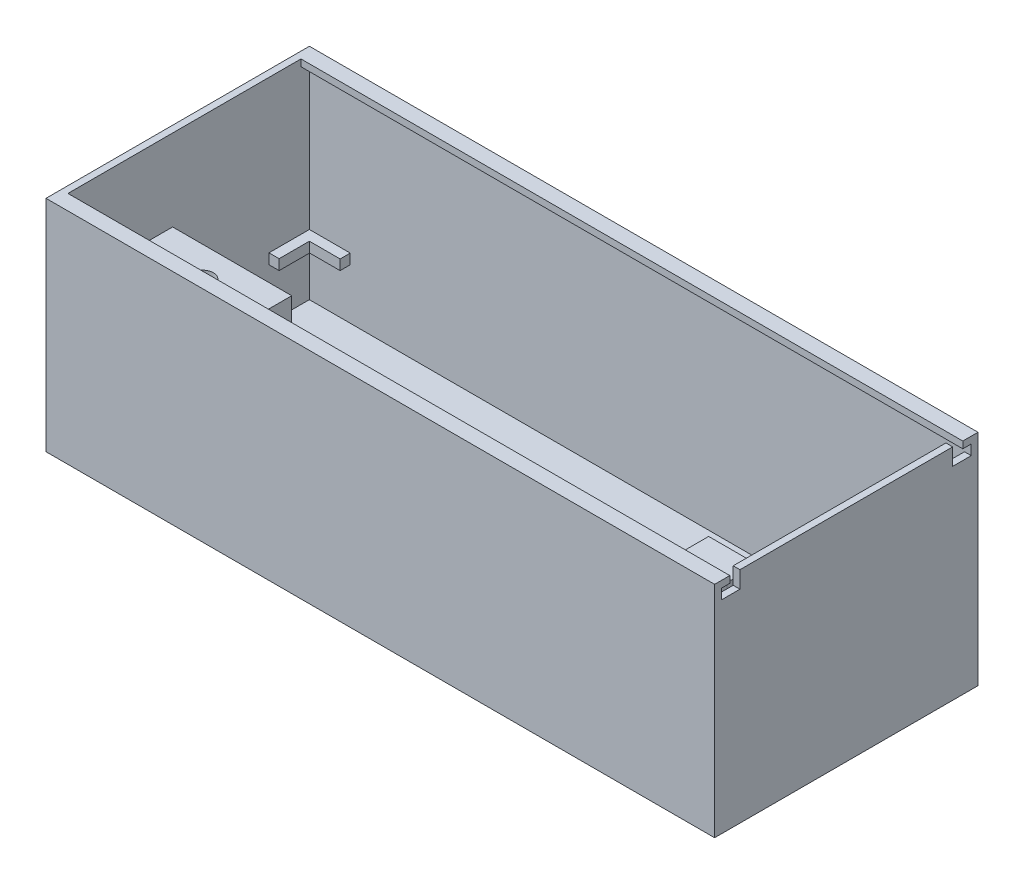
from build123d import *

# Parameters (mm, degrees)
SKETCH2_W                = 198
SKETCH2_H                = 78
BOSS_EXTRUDE1_DEPTH      = 50
BOSS_EXTRUDE1_DEPTH_BACK = 15
SHELL1_T                 = -2
BOSS_EXTRUDE2_REACH      = 198
SKETCH3_W                = 2.5
SKETCH3_H                = 2
CUT_EXTRUDE1_REACH       = 4
CROQUIS1_W               = 35.265
CROQUIS1_H               = 26
SALIENTE_EXTRUIR1_DEPTH  = 38.9
CORTAR_EXTRUIR1_DEPTH    = 2
CORTAR_EXTRUIR2_DEPTH    = 30
CROQUIS5_W               = 26
CROQUIS5_H               = 15
CORTAR_EXTRUIR3_DEPTH    = 35.265
CROQUIS6_W               = 12
CROQUIS6_H               = 3
SALIENTE_EXTRUIR2_DEPTH  = 3
CROQUIS7_W               = 26
CROQUIS7_H               = 15
CORTAR_EXTRUIR4_DEPTH    = 35.265
CROQUIS8_W               = 12
CROQUIS8_H               = 3
SALIENTE_EXTRUIR4_DEPTH  = 3
CROQUIS10_W              = 12.009872988
CROQUIS10_H              = 3
SALIENTE_EXTRUIR5_DEPTH  = 3
CROQUIS11_W              = 12.098159715
CROQUIS11_H              = 3
SALIENTE_EXTRUIR6_DEPTH  = 3
CROQUIS12_W              = 11.962837464
CROQUIS12_H              = 3.064497362
SALIENTE_EXTRUIR7_DEPTH  = 3


with BuildPart() as part:
    # Sketch2 → Boss-Extrude1 (new body, two sides)
    with BuildSketch(Plane(origin=(0, 0, 0), x_dir=(1, 0, 0), z_dir=(0, 1, 0))) as boss_extrude1_sk:
        Rectangle(SKETCH2_W, SKETCH2_H)
    extrude(amount=BOSS_EXTRUDE1_DEPTH)
    extrude(boss_extrude1_sk.sketch, amount=-BOSS_EXTRUDE1_DEPTH_BACK)

    # Shell1
    shell1_openings = [part.faces().sort_by_distance(p)[0] for p in [
        (0, 50, 0),
    ]]
    offset(amount=SHELL1_T, openings=shell1_openings, kind=Kind.INTERSECTION)

    # Sketch3 → Boss-Extrude2 (add, up to next)
    with BuildSketch(Plane(origin=(-97, 0, 0), x_dir=(0, 0, -1), z_dir=(1, 0, 0)), mode=Mode.PRIVATE) as boss_extrude2_sk1:
        with Locations((-35.75, 49)):
            Rectangle(SKETCH3_W, SKETCH3_H)
    boss_extrude2_tool1 = extrude(boss_extrude2_sk1.sketch, amount=BOSS_EXTRUDE2_REACH, mode=Mode.PRIVATE) - part.part
    add(boss_extrude2_tool1.solids().sort_by_distance((-97, 49, 35.75))[0])
    # Sketch3 → Boss-Extrude2 (add, up to next)
    with BuildSketch(Plane(origin=(-97, 0, 0), x_dir=(0, 0, -1), z_dir=(1, 0, 0)), mode=Mode.PRIVATE) as boss_extrude2_sk2:
        with Locations((35.75, 49)):
            Rectangle(SKETCH3_W, SKETCH3_H)
    boss_extrude2_tool2 = extrude(boss_extrude2_sk2.sketch, amount=BOSS_EXTRUDE2_REACH, mode=Mode.PRIVATE) - part.part
    add(boss_extrude2_tool2.solids().sort_by_distance((-97, 49, -35.75))[0])

    # Sketch4 → Cut-Extrude1 (cut, up to next)
    with BuildSketch(Plane.ZY.offset(-97), mode=Mode.PRIVATE) as cut_extrude1_sk1:
        Polygon((-37, 48), (-37, 45), (-31.5, 45), (-31.5, 50), (-34.5, 50), (-34.5, 48), align=None)
    cut_extrude1_tool1 = extrude(cut_extrude1_sk1.sketch, amount=-CUT_EXTRUDE1_REACH, mode=Mode.PRIVATE) & part.part
    add(cut_extrude1_tool1.solids().sort_by_distance((97, 47.166667, -33.916667))[0], mode=Mode.SUBTRACT)
    # Sketch4 → Cut-Extrude1 (cut, up to next)
    with BuildSketch(Plane.ZY.offset(-97), mode=Mode.PRIVATE) as cut_extrude1_sk2:
        Polygon((34.5, 48), (37, 48), (37, 45), (31.5, 45), (31.5, 50), (34.5, 50), align=None)
    cut_extrude1_tool2 = extrude(cut_extrude1_sk2.sketch, amount=-CUT_EXTRUDE1_REACH, mode=Mode.PRIVATE) & part.part
    add(cut_extrude1_tool2.solids().sort_by_distance((97, 47.166667, 33.916667))[0], mode=Mode.SUBTRACT)

    # Croquis1 → Saliente-Extruir1 (add)
    with BuildSketch(Plane(origin=(0, -13, 0), x_dir=(1, 0, 0), z_dir=(0, 1, 0))):
        with Locations((79.3675, -16.5)):
            Rectangle(CROQUIS1_W, CROQUIS1_H)
    saliente_extruir1 = extrude(amount=SALIENTE_EXTRUIR1_DEPTH)

    # Simetría1: Saliente-Extruir1 across plane
    add(saliente_extruir1.mirror(Plane(origin=(0, 0, 0), x_dir=(0, 0, 1), z_dir=(1, 0, 0))))

    # Croquis2 → Cortar-Extruir1 (cut)
    with BuildSketch(Plane(origin=(0, 25.9, 0), x_dir=(1, 0, 0), z_dir=(0, 1, 0))):
        with BuildLine():
            Line((82.41, -12.375), (82.41, -20.625))
            ThreePointArc((82.41, -20.625), (79.235, -23.8), (76.06, -20.625))
            Line((76.06, -20.625), (76.06, -12.375))
            ThreePointArc((76.06, -12.375), (79.235, -9.2), (82.41, -12.375))
        make_face()
    cortar_extruir1 = extrude(amount=-CORTAR_EXTRUIR1_DEPTH, mode=Mode.SUBTRACT)

    # Simetría2: Cortar-Extruir1 across plane
    add(cortar_extruir1.mirror(Plane(origin=(0, 0, 0), x_dir=(0, 0, 1), z_dir=(1, 0, 0))), mode=Mode.SUBTRACT)

    # Croquis3 → Cortar-Extruir2 (cut)
    with BuildSketch(Plane(origin=(0, 23.9, 0), x_dir=(1, 0, 0), z_dir=(0, 1, 0))):
        with BuildLine():
            Line((80.835, -13.2), (80.835, -19.8))
            ThreePointArc((80.835, -19.8), (79.235, -21.4), (77.635, -19.8))
            Line((77.635, -19.8), (77.635, -13.2))
            ThreePointArc((77.635, -13.2), (79.235, -11.6), (80.835, -13.2))
        make_face()
    cortar_extruir2 = extrude(amount=-CORTAR_EXTRUIR2_DEPTH, mode=Mode.SUBTRACT)

    # Simetría3: Cortar-Extruir2 across plane
    add(cortar_extruir2.mirror(Plane(origin=(0, 0, 0), x_dir=(0, 0, 1), z_dir=(1, 0, 0))), mode=Mode.SUBTRACT)

    # Croquis5 → Cortar-Extruir3 (cut)
    with BuildSketch(Plane.ZY.offset(-61.735)):
        with Locations((16.5, -5.5)):
            Rectangle(CROQUIS5_W, CROQUIS5_H)
    extrude(amount=-CORTAR_EXTRUIR3_DEPTH, mode=Mode.SUBTRACT)

    # Croquis6 → Saliente-Extruir2 (add)
    with BuildSketch(Plane.ZY.offset(-61.735)):
        with Locations((16.5, 3.5)):
            Rectangle(CROQUIS6_W, CROQUIS6_H)
    saliente_extruir2 = extrude(amount=SALIENTE_EXTRUIR2_DEPTH)

    # Croquis7 → Cortar-Extruir4 (cut)
    with BuildSketch(Plane(origin=(-61.735, 0, 0), x_dir=(0, 0, -1), z_dir=(1, 0, 0))):
        with Locations((-16.5, -5.5)):
            Rectangle(CROQUIS7_W, CROQUIS7_H)
    extrude(amount=-CORTAR_EXTRUIR4_DEPTH, mode=Mode.SUBTRACT)

    # Simetría7: Saliente-Extruir2 across plane
    add(saliente_extruir2.mirror(Plane(origin=(0, 0, 0), x_dir=(0, 0, 1), z_dir=(1, 0, 0))))

    # Croquis8 → Saliente-Extruir4 (add)
    with BuildSketch(Plane.XY.offset(-37)):
        with Locations((91, 3.5)):
            Rectangle(CROQUIS8_W, CROQUIS8_H)
    extrude(amount=SALIENTE_EXTRUIR4_DEPTH)

    # Croquis10 → Saliente-Extruir5 (add)
    with BuildSketch(Plane.ZY.offset(-97)):
        with Locations((-30.995063506, 3.5)):
            Rectangle(CROQUIS10_W, CROQUIS10_H)
    extrude(amount=SALIENTE_EXTRUIR5_DEPTH)

    # Croquis11 → Saliente-Extruir6 (add)
    with BuildSketch(Plane.XY.offset(-37)):
        with Locations((-90.950920142, 3.5)):
            Rectangle(CROQUIS11_W, CROQUIS11_H)
    extrude(amount=SALIENTE_EXTRUIR6_DEPTH)

    # Croquis12 → Saliente-Extruir7 (add)
    with BuildSketch(Plane(origin=(-97, 0, 0), x_dir=(0, 0, -1), z_dir=(1, 0, 0))):
        with Locations((31.018581268, 3.467751319)):
            Rectangle(CROQUIS12_W, CROQUIS12_H)
    extrude(amount=SALIENTE_EXTRUIR7_DEPTH)


solid = part.part
